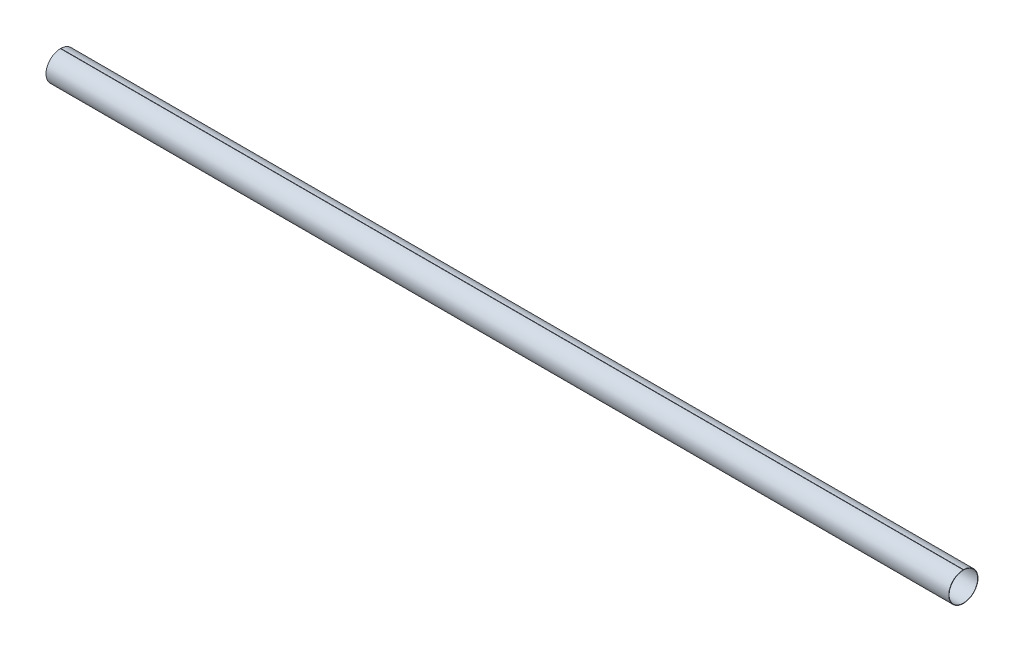
from build123d import *

# Parameters (mm, degrees)
BOSS_EXTRUDE1_DEPTH = 2500


with BuildPart() as part:
    # Sketch1 → Boss-Extrude1 (new body)
    with BuildSketch(Plane(origin=(0, 0, 0), x_dir=(0, 0, -1), z_dir=(1, 0, 0))):
        with BuildLine():
            Line((-0.5, 40.496913463), (-0.5, 39.496835316))
            ThreePointArc((-0.5, 39.496835316), (0, -39.5), (0.5, 39.496835316))
            Line((0.5, 39.496835316), (0.5, 40.496913463))
            ThreePointArc((0.5, 40.496913463), (0, -40.5), (-0.5, 40.496913463))
        make_face()
    extrude(amount=BOSS_EXTRUDE1_DEPTH)


solid = part.part
